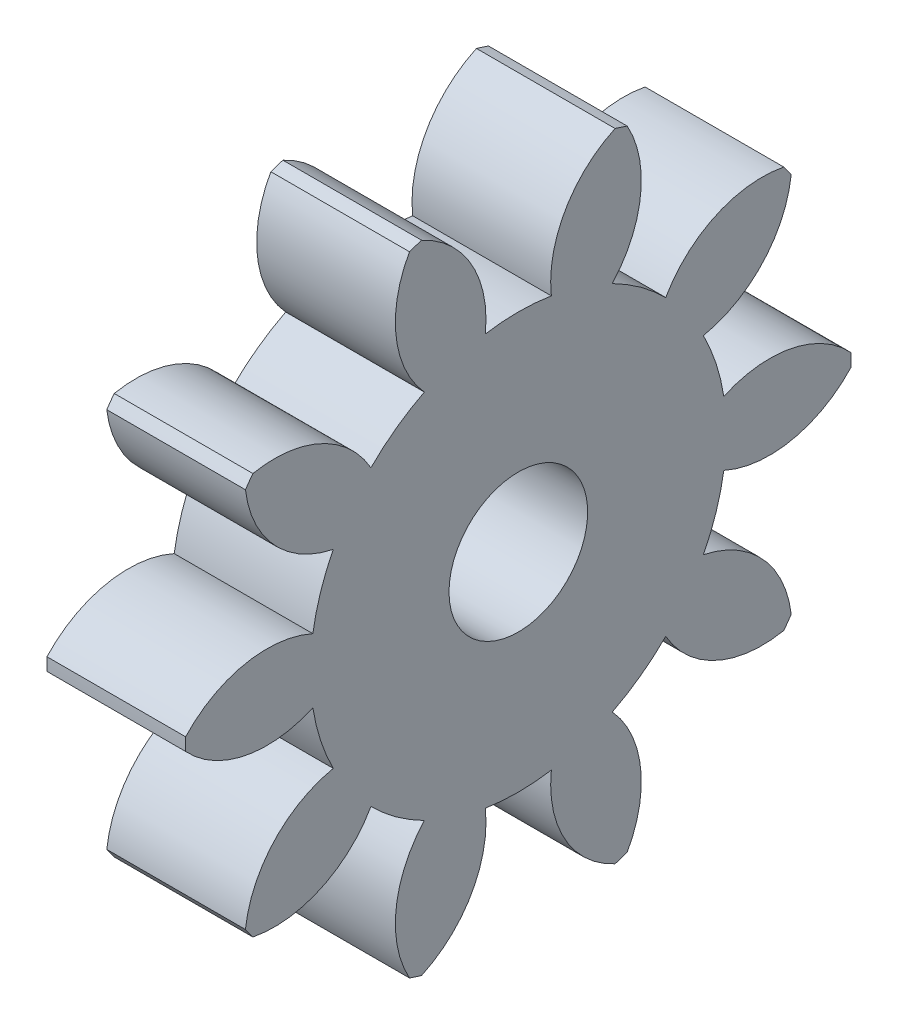
from build123d import *

# Parameters (mm, degrees)
BASPROSKE_W        = 6.35
BASPROSKE_H        = 15.24
TOOTHCUT_DEPTH     = 23.468593636
TEETHCUTS_COUNT    = 10
TEETHCUTS_ANGLE    = 324
BORSKE_R           = 0.396875
BORE_DEPTH         = 50.8000508
KEYSKE_W           = 0.254
KEYSKE_H           = 0.619125
KEYWAY_DEPTH       = 50.8000508
SKETCH1_R          = 3.175
CUT_EXTRUDE1_DEPTH = 23.027224313


with BuildPart() as part:
    # BasProSke → Base-Revolve (revolve)
    with BuildSketch(Plane(origin=(0, 0, 0), x_dir=(1, 0, 0), z_dir=(0, 1, 0)), mode=Mode.PRIVATE) as base_revolve_sk:
        with Locations((3.175, 7.62)):
            Rectangle(BASPROSKE_W, BASPROSKE_H)
    revolve(base_revolve_sk.sketch.rotate(Axis((-10, 0, 0), (1, 0, 0)), 180), axis=Axis((-10, 0, 0), (1, 0, 0)))

    # TooCutSke → ToothCut (cut, through all)
    with BuildSketch(Plane(origin=(0, 0, 0), x_dir=(0, 0, -1), z_dir=(1, 0, 0))):
        with BuildLine():
            ThreePointArc((1.512171166, 9.402912925), (0, 9.52373), (-1.512171166, 9.402912925))
            ThreePointArc((-1.512171166, 9.402912925), (-2.144739364, 12.480481638), (-4.466452315, 14.597371026))
            ThreePointArc((-4.466452315, 14.597371026), (0, 15.2654), (4.466452315, 14.597371026))
            ThreePointArc((4.466452315, 14.597371026), (2.144739364, 12.480481638), (1.512171166, 9.402912925))
        make_face()
    toothcut = extrude(amount=TOOTHCUT_DEPTH, mode=Mode.SUBTRACT)

    # TeethCuts: ToothCut ×10 about axis
    teethcuts_axis = Axis((-10, 0, 0), (1, 0, 0))
    for i in range(1, TEETHCUTS_COUNT):
        add(toothcut.rotate(teethcuts_axis, i * TEETHCUTS_ANGLE / (TEETHCUTS_COUNT - 1)), mode=Mode.SUBTRACT)

    # BorSke → Bore (cut, symmetric)
    with BuildSketch(Plane(origin=(0, 0, 0), x_dir=(0, 0, -1), z_dir=(1, 0, 0))):
        with Locations(Location((0, 0, 0), (0, 0, 180))):
            Circle(BORSKE_R)
    extrude(amount=BORE_DEPTH, both=True, mode=Mode.SUBTRACT)

    # KeySke → Keyway (cut, symmetric)
    with BuildSketch(Plane(origin=(0, 0, 0), x_dir=(0, 0, -1), z_dir=(1, 0, 0))):
        with Locations((0, 0.3095625)):
            Rectangle(KEYSKE_W, KEYSKE_H)
    extrude(amount=KEYWAY_DEPTH, both=True, mode=Mode.SUBTRACT)

    # Sketch1 → Cut-Extrude1 (cut, through all)
    with BuildSketch(Plane.ZY):
        Circle(SKETCH1_R)
    extrude(amount=-CUT_EXTRUDE1_DEPTH, mode=Mode.SUBTRACT)


solid = part.part
